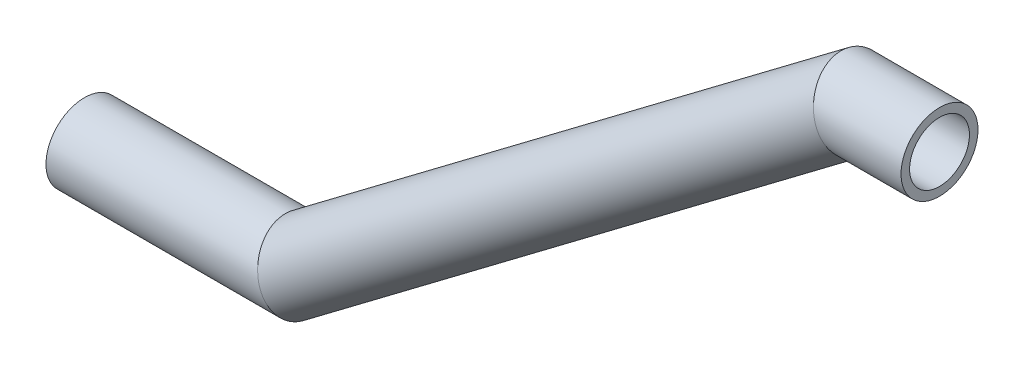
from build123d import *

# Parameters (mm, degrees)
SKETCH2_R   = 4.5
SKETCH2_R_2 = 3.5


with BuildPart() as part:
    # Sweep1: sweep along a path in Sketch1
    with BuildLine(Plane.XY) as sweep1_path:
        Line((-25, 0), (0, 0))
        Line((0, 0), (65, 49))
        Line((65, 49), (75, 49))
    # Sketch2 → Sweep1 (sweep)
    with BuildSketch(Plane(origin=(0, 0, 0), x_dir=(0, 0, -1), z_dir=(1, 0, 0))):
        Circle(SKETCH2_R)
        Circle(SKETCH2_R_2, mode=Mode.SUBTRACT)
    sweep(path=sweep1_path.line, transition=Transition.RIGHT)


solid = part.part
